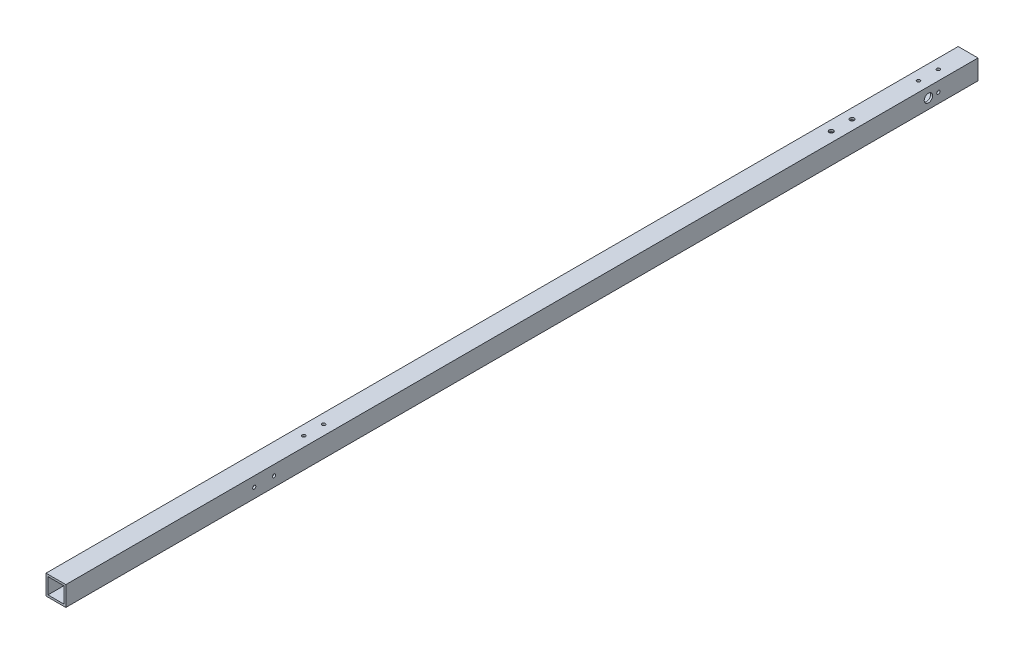
from build123d import *

# Parameters (mm, degrees)
SKETCH_1_W           = 20
SKETCH_1_H           = 20
SKETCH_1_W_2         = 16
SKETCH_1_H_2         = 16
EXTRUDE_1_DEPTH      = 970
SKETCH_2_R           = 1
SKETCH_2_R_2         = 4.25
CUT_EXTRUDE_1_DEPTH  = 10
CUT_EXTRUDE_2_DEPTH  = 10
SKETCH_5_R           = 2.2
CUT_EXTRUDE_7_DEPTH  = 30
SKETCH_6_W           = 27.825743136
SKETCH_6_H           = 21.841712354
CUT_EXTRUDE_8_DEPTH  = 50
M4X0_7_3_D           = 3.3
M4X0_7_3_DEPTH       = 11.5
M4X0_7_3_TIP         = 0.991420021
SKETCH_11_R          = 1
CUT_EXTRUDE_9_DEPTH  = 10
M4X0_7_4_D           = 3.3
M4X0_7_4_DEPTH       = 11.5
M4X0_7_4_TIP         = 0.991420021
SKETCH_13_R          = 4.25
CUT_EXTRUDE_10_DEPTH = 21
M4X0_7_5_D           = 3.3
M4X0_7_5_DEPTH       = 11.5
M4X0_7_5_TIP         = 0.991420021


with BuildPart() as part:
    # ｽｹｯﾁ1 → ﾎﾞｽ - 押し出し1 (new body)
    with BuildSketch(Plane.XY):
        Rectangle(SKETCH_1_W, SKETCH_1_H)
        Rectangle(SKETCH_1_W_2, SKETCH_1_H_2, mode=Mode.SUBTRACT)
    extrude(amount=EXTRUDE_1_DEPTH)

    # ｽｹｯﾁ2 → ｶｯﾄ - 押し出し1 (cut)
    with BuildSketch(Plane(origin=(10, 0, 0), x_dir=(0, 0, -1), z_dir=(1, 0, 0))):
        with Locations((-710, 0)):
            Circle(SKETCH_2_R)
        with Locations((-50, 0)):
            Circle(SKETCH_2_R_2)
        with Locations((-40, 0)):
            Circle(SKETCH_2_R)
        with Locations((-730, 0)):
            Circle(SKETCH_2_R)
    extrude(amount=-CUT_EXTRUDE_1_DEPTH, mode=Mode.SUBTRACT)

    # ｽｹｯﾁ3 → ｶｯﾄ - 押し出し2 (cut)
    with BuildSketch(Plane(origin=(0, 10, 0), x_dir=(1, 0, 0), z_dir=(0, 1, 0))):
        with BuildLine():
            ThreePointArc((0, -649), (-1, -650), (0, -651))
            Line((0, -651), (0, -650))
            Line((0, -650), (0, -649))
        make_face()
        with BuildLine():
            Line((0, -650), (0, -651))
            ThreePointArc((0, -651), (0.707106781, -650.707106781), (1, -650))
            ThreePointArc((1, -650), (0.707106781, -649.292893219), (0, -649))
            Line((0, -649), (0, -650))
        make_face()
        with BuildLine():
            ThreePointArc((0, -669), (-1, -670), (0, -671))
            Line((0, -671), (0, -670))
            Line((0, -670), (0, -669))
        make_face()
        with BuildLine():
            Line((0, -670), (0, -671))
            ThreePointArc((0, -671), (0.707106781, -670.707106781), (1, -670))
            ThreePointArc((1, -670), (0.707106781, -669.292893219), (0, -669))
            Line((0, -669), (0, -670))
        make_face()
    extrude(amount=-CUT_EXTRUDE_2_DEPTH, mode=Mode.SUBTRACT)

    # ｽｹｯﾁ5 → ｶｯﾄ - 押し出し7 (cut)
    with BuildSketch(Plane(origin=(0, 10, 0), x_dir=(1, 0, 0), z_dir=(0, 1, 0))):
        with Locations((0, -117)):
            Circle(SKETCH_5_R)
        with Locations((0, -138)):
            Circle(SKETCH_5_R)
    extrude(amount=-CUT_EXTRUDE_7_DEPTH, mode=Mode.SUBTRACT)

    # ｽｹｯﾁ6 → ｶｯﾄ - 押し出し8 (cut)
    with BuildSketch(Plane.XY.offset(970)):
        Rectangle(SKETCH_6_W, SKETCH_6_H)
    extrude(amount=-CUT_EXTRUDE_8_DEPTH, mode=Mode.SUBTRACT)

    # M4x0.7 ねじ穴3
    with Locations(Plane(origin=(0, 10, 650), x_dir=(1, 0, 0), z_dir=(0, 1, 0))):
        with Locations((0, 0), (0, -20)):
            Hole(M4X0_7_3_D / 2, depth=M4X0_7_3_DEPTH)
            with Locations((0, 0, -(M4X0_7_3_DEPTH + M4X0_7_3_TIP / 2))):  # 118° drill point
                Cone(0, M4X0_7_3_D / 2, M4X0_7_3_TIP, mode=Mode.SUBTRACT)

    # ｽｹｯﾁ11 → ｶｯﾄ - 押し出し9 (cut)
    with BuildSketch(Plane(origin=(0, 10, 0), x_dir=(1, 0, 0), z_dir=(0, 1, 0))):
        with Locations((0, -30)):
            Circle(SKETCH_11_R)
        with Locations((0, -50)):
            Circle(SKETCH_11_R)
    extrude(amount=-CUT_EXTRUDE_9_DEPTH, mode=Mode.SUBTRACT)

    # M4x0.7 ねじ穴4
    with Locations(Plane(origin=(0, 10, 30), x_dir=(1, 0, 0), z_dir=(0, 1, 0))):
        with Locations((0, 0), (0, -20)):
            Hole(M4X0_7_4_D / 2, depth=M4X0_7_4_DEPTH)
            with Locations((0, 0, -(M4X0_7_4_DEPTH + M4X0_7_4_TIP / 2))):  # 118° drill point
                Cone(0, M4X0_7_4_D / 2, M4X0_7_4_TIP, mode=Mode.SUBTRACT)

    # ｽｹｯﾁ13 → ｶｯﾄ - 押し出し10 (cut, through all)
    with BuildSketch(Plane(origin=(10, 0, 0), x_dir=(0, 0, -1), z_dir=(1, 0, 0))):
        with Locations((-50, 0)):
            Circle(SKETCH_13_R)
    extrude(amount=-CUT_EXTRUDE_10_DEPTH, mode=Mode.SUBTRACT)

    # M4x0.7 ねじ穴5
    with Locations(Plane(origin=(10, 0, 40), x_dir=(0, 0, 1), z_dir=(1, 0, 0))):
        with Locations((0, 0), (670, 0), (690, 0)):
            Hole(M4X0_7_5_D / 2, depth=M4X0_7_5_DEPTH)
            with Locations((0, 0, -(M4X0_7_5_DEPTH + M4X0_7_5_TIP / 2))):  # 118° drill point
                Cone(0, M4X0_7_5_D / 2, M4X0_7_5_TIP, mode=Mode.SUBTRACT)


solid = part.part
